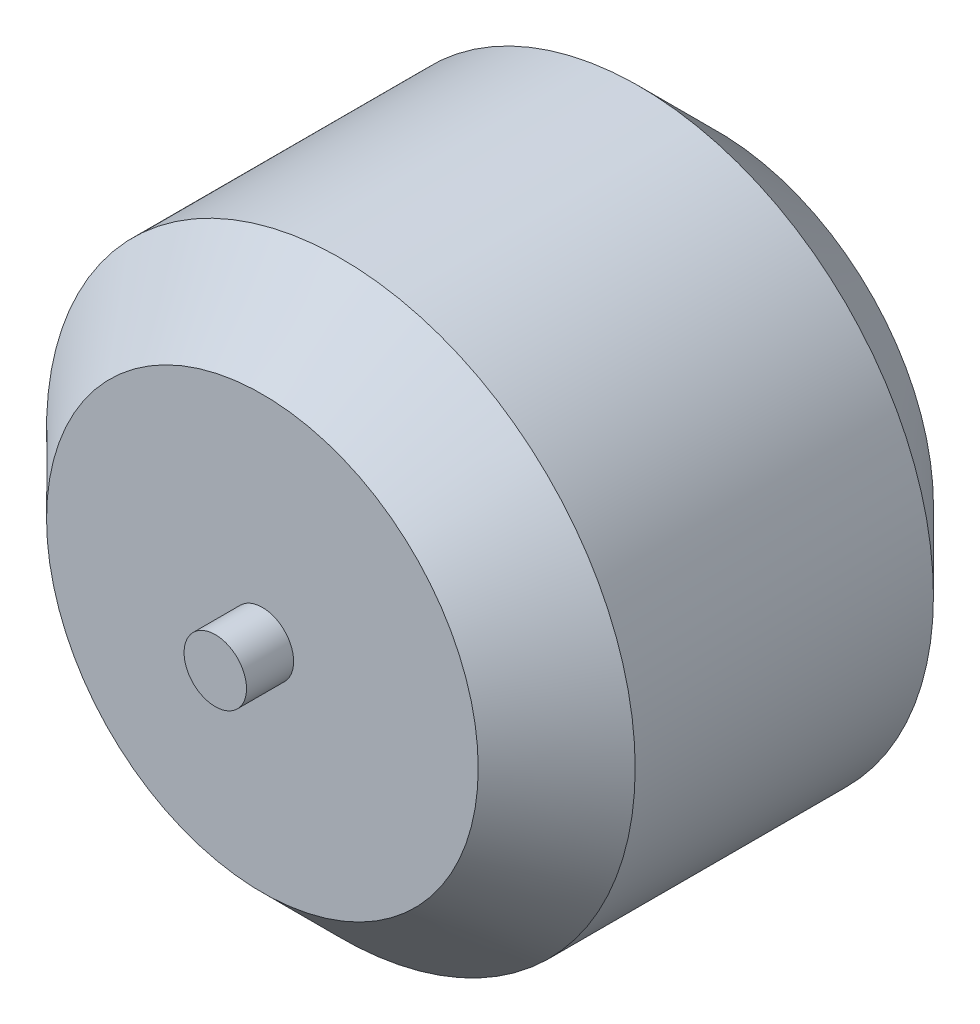
from build123d import *

# Parameters (mm, degrees)
SKETCH1_R           = 18.75
BOSS_EXTRUDE1_DEPTH = 29
SKETCH3_R           = 1.99
BOSS_EXTRUDE4_DEPTH = 3
CHAMFER1_SIZE       = 5
SKETCH4_R           = 1.99
BOSS_EXTRUDE5_DEPTH = 1
SKETCH5_R           = 1.5
CUT_EXTRUDE1_DEPTH  = 1
CIRPATTERN1_COUNT   = 4


with BuildPart() as part:
    # Sketch1 → Boss-Extrude1 (new body)
    with BuildSketch(Plane.XY):
        Circle(SKETCH1_R)
    extrude(amount=BOSS_EXTRUDE1_DEPTH)

    # Sketch3 → Boss-Extrude4 (add)
    with BuildSketch(Plane.XY.offset(29)):
        Circle(SKETCH3_R)
    extrude(amount=BOSS_EXTRUDE4_DEPTH)

    # Chamfer1
    chamfer1_edges = [part.edges().sort_by_distance(p)[0] for p in [
        (-18.75, 0, 0),
        (-18.75, 0, 29),
    ]]
    chamfer(chamfer1_edges, length=CHAMFER1_SIZE)

    # Sketch4 → Boss-Extrude5 (add)
    with BuildSketch(Plane(origin=(0, 0, 0), x_dir=(-1, 0, 0), z_dir=(0, 0, -1))):
        Circle(SKETCH4_R)
    extrude(amount=BOSS_EXTRUDE5_DEPTH)

    # Sketch5 → Cut-Extrude1 (cut)
    with BuildSketch(Plane(origin=(0, 0, 0), x_dir=(-1, 0, 0), z_dir=(0, 0, -1))):
        with Locations((0, 8)):
            Circle(SKETCH5_R)
    cut_extrude1 = extrude(amount=-CUT_EXTRUDE1_DEPTH, mode=Mode.SUBTRACT)

    # CirPattern1: Cut-Extrude1 ×4 about axis
    cirpattern1_axis = Axis((0, 0, 0), (0, 0, 1))
    for i in range(1, CIRPATTERN1_COUNT):
        add(cut_extrude1.rotate(cirpattern1_axis, i * 360 / CIRPATTERN1_COUNT), mode=Mode.SUBTRACT)


solid = part.part
